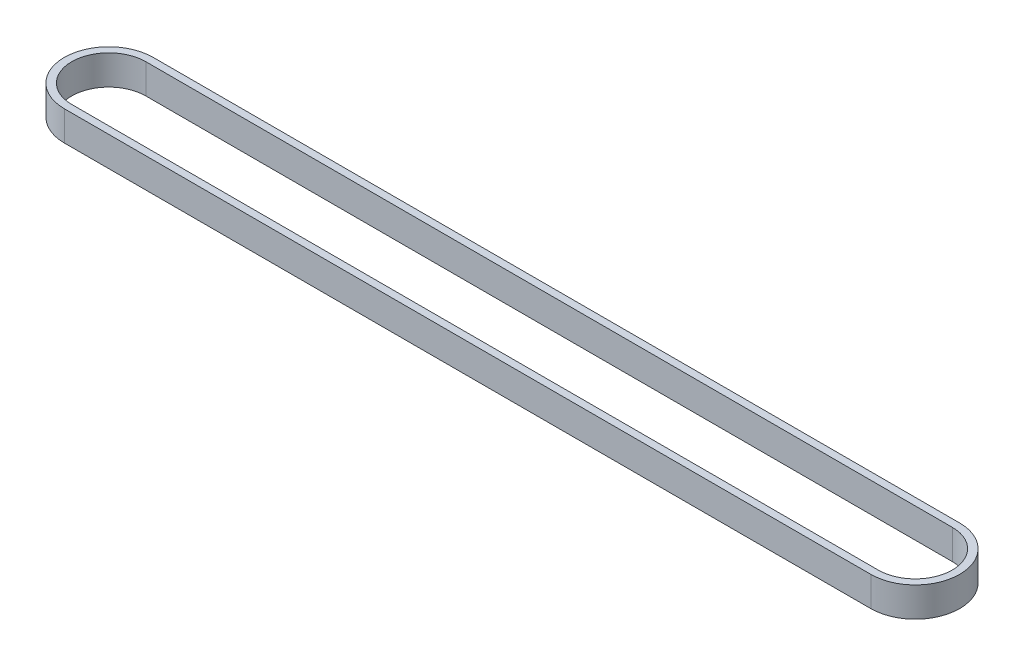
from build123d import *

# Parameters (mm, degrees)
BOSS_EXTRUDE2_DEPTH = 8
CUT_EXTRUDE1_DEPTH  = 9


with BuildPart() as part:
    # Sketch1 → Boss-Extrude2 (new body)
    with BuildSketch(Plane(origin=(0, 0, 0), x_dir=(1, 0, 0), z_dir=(0, 1, 0))):
        with BuildLine():
            Line((0, 11.975), (217.26, 11.975))
            ThreePointArc((217.26, 11.975), (229.235, 0), (217.26, -11.975))
            Line((217.26, -11.975), (0, -11.975))
            ThreePointArc((0, -11.975), (-11.975, 0), (0, 11.975))
        make_face()
    extrude(amount=BOSS_EXTRUDE2_DEPTH)

    # Sketch2 → Cut-Extrude1 (cut, through all)
    with BuildSketch(Plane(origin=(0, 8, 0), x_dir=(1, 0, 0), z_dir=(0, 1, 0))):
        with BuildLine():
            Line((0, 9.975), (217.26, 9.975))
            ThreePointArc((217.26, 9.975), (227.235, 0), (217.26, -9.975))
            Line((217.26, -9.975), (0, -9.975))
            ThreePointArc((0, -9.975), (-9.975, 0), (0, 9.975))
        make_face()
    extrude(amount=-CUT_EXTRUDE1_DEPTH, mode=Mode.SUBTRACT)


solid = part.part
